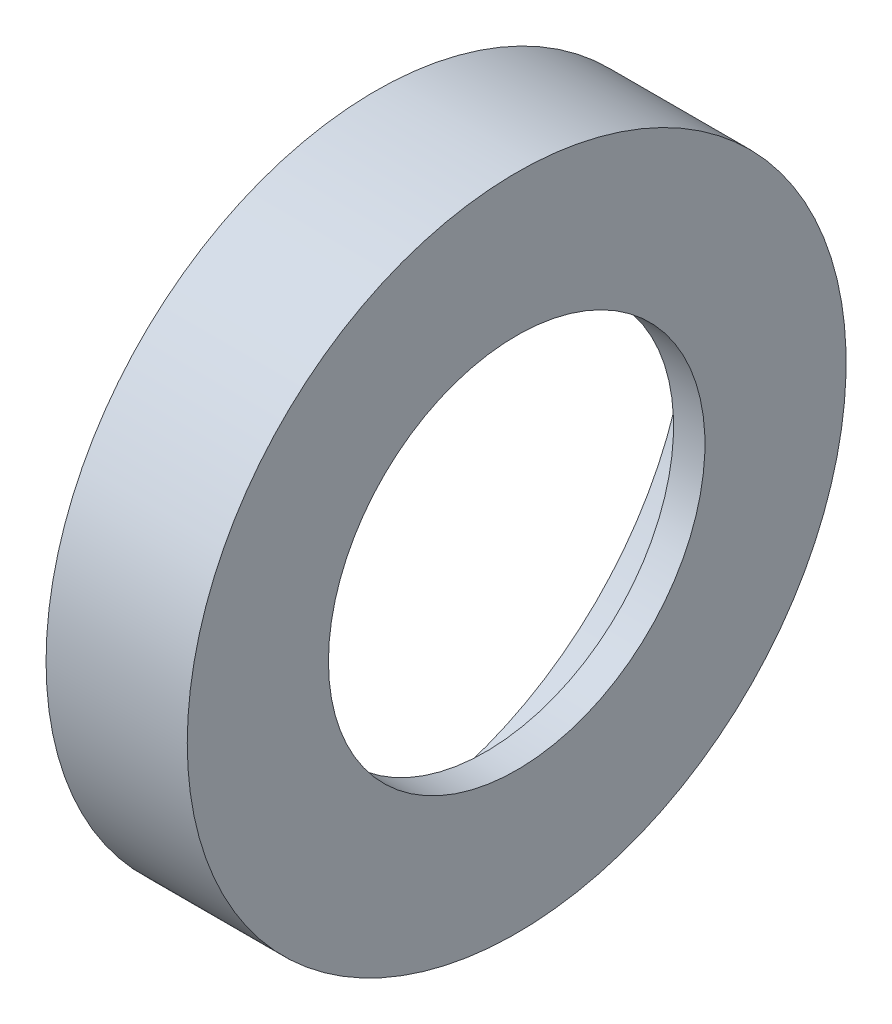
from build123d import *


with BuildPart() as part:
    # Esquisse1 → Révolution1 (revolve)
    with BuildSketch(Plane.XY):
        Polygon((0, 24), (0, 42), (-18, 42), (-18, 40), (-8, 40), (-8, 37.65), (-4, 37.65), (-4, 24), align=None)
    revolve(axis=Axis((-32.852795702, 0, 0), (1, 0, 0)))


solid = part.part
